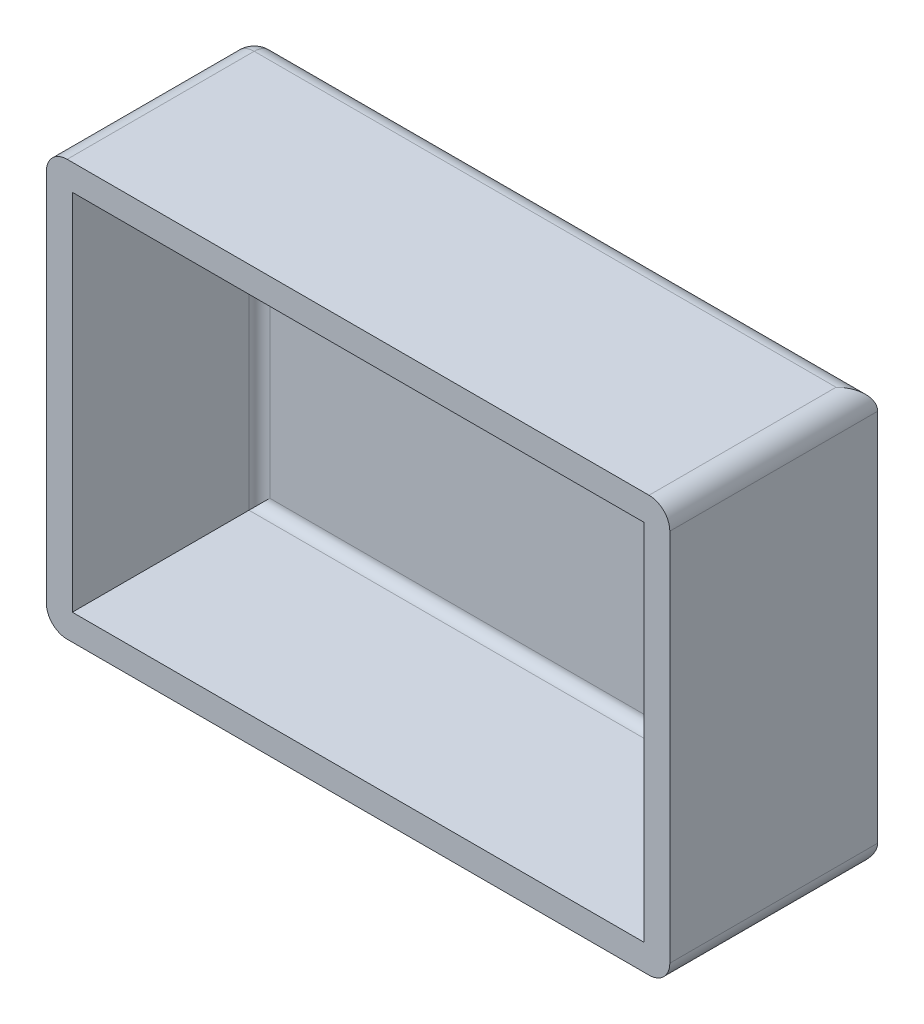
from build123d import *

# Parameters (mm, degrees)
SKETCH1_W           = 60
SKETCH1_H           = 40
BOSS_EXTRUDE1_DEPTH = 20
SKETCH2_W           = 55
SKETCH2_H           = 35
CUT_EXTRUDE1_DEPTH  = 18
FILLET1_R           = 1
FILLET2_R           = 2


with BuildPart() as part:
    # Sketch1 → Boss-Extrude1 (new body)
    with BuildSketch(Plane.XY):
        Rectangle(SKETCH1_W, SKETCH1_H)
    extrude(amount=BOSS_EXTRUDE1_DEPTH)

    # Sketch2 → Cut-Extrude1 (cut)
    with BuildSketch(Plane.XY.offset(20)):
        Rectangle(SKETCH2_W, SKETCH2_H)
    extrude(amount=-CUT_EXTRUDE1_DEPTH, mode=Mode.SUBTRACT)

    # Fillet1
    fillet1_edges = [part.edges().sort_by_distance(p)[0] for p in [
        (27.5, 0, 2),
        (0, -17.5, 2),
        (-27.5, 0, 2),
        (0, 17.5, 2),
    ]]
    fillet(fillet1_edges, radius=FILLET1_R)

    # Fillet2
    fillet2_edges = [part.edges().sort_by_distance(p)[0] for p in [
        (0, -20, 0),
        (-30, 0, 0),
        (0, 20, 0),
        (30, -20, 10),
        (-30, -20, 10),
        (-30, 20, 10),
        (30, 20, 10),
    ]]
    fillet(fillet2_edges, radius=FILLET2_R)


solid = part.part
